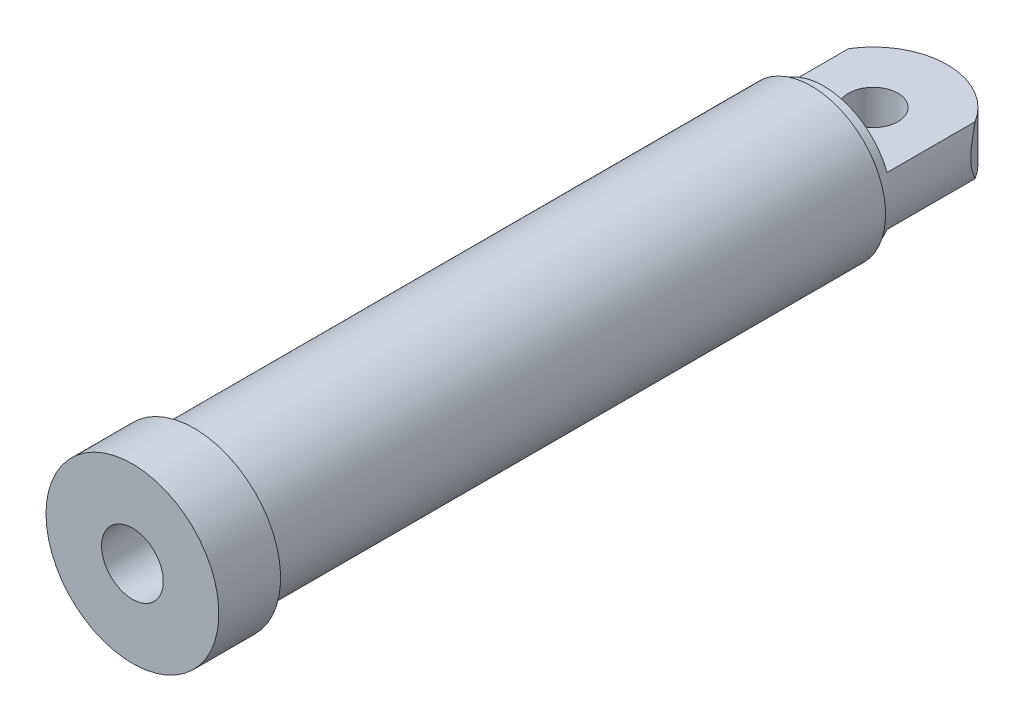
from build123d import *

# Parameters (mm, degrees)
SKETCH2_R               = 20
BOSS_EXTRUDE1_DEPTH     = 20
SKETCH3_R               = 63.245553203
SKETCH3_R_2             = 55
CUT_EXTRUDE1_DEPTH      = 101
CUT_EXTRUDE1_DEPTH_BACK = 10


with BuildPart() as part:
    # Sketch1 → Revolve1 (revolve)
    with BuildSketch(Plane(origin=(0, 0, 0), x_dir=(1, 0, 0), z_dir=(0, 1, 0))):
        Polygon((70, -600), (70, -550), (60, -550), (60, -40), (0, -40), (0, -60), (45, -60), (45, -520), (25, -520), (25, -600), align=None)
    revolve(axis=Axis((0, 0, 0), (0, 0, 1)))

    # Sketch2 → Boss-Extrude1 (add, symmetric)
    with BuildSketch(Plane(origin=(0, 0, 0), x_dir=(1, 0, 0), z_dir=(0, 1, 0))):
        with BuildLine():
            Line((60, -40), (60, 0))
            ThreePointArc((60, 0), (0, 60), (-60, 0))
            Line((-60, 0), (-60, -40))
            Line((-60, -40), (60, -40))
        make_face()
        Circle(SKETCH2_R, mode=Mode.SUBTRACT)
    extrude(amount=BOSS_EXTRUDE1_DEPTH, both=True)

    # Sketch3 → Cut-Extrude1 (cut, two sides)
    with BuildSketch(Plane(origin=(0, 0, 40), x_dir=(-1, 0, 0), z_dir=(0, 0, -1))) as cut_extrude1_sk:
        Circle(SKETCH3_R)
        Circle(SKETCH3_R_2, mode=Mode.SUBTRACT)
    extrude(amount=CUT_EXTRUDE1_DEPTH, mode=Mode.SUBTRACT)
    extrude(cut_extrude1_sk.sketch, amount=-CUT_EXTRUDE1_DEPTH_BACK, mode=Mode.SUBTRACT)


solid = part.part
